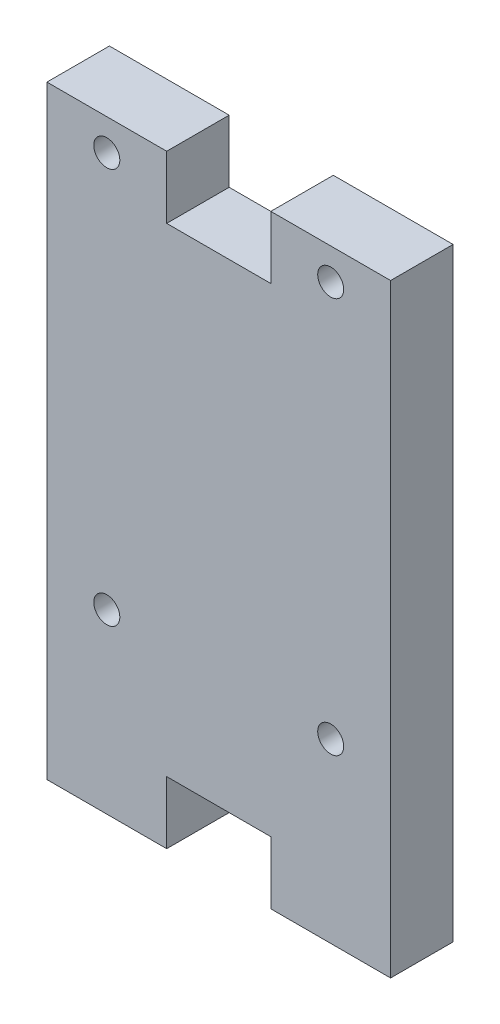
from build123d import *

# Parameters (mm, degrees)
BOSS_EXTRU_1_DEPTH      = 6
ESQUISSE2_R             = 1.25
ENL_V_MAT_EXTRU_1_DEPTH = 6


with BuildPart() as part:
    # Esquisse1 → Boss.-Extru.1 (new body)
    with BuildSketch(Plane.XY):
        Polygon((-16.5, 22), (-5, 22), (-5, 16), (5, 16), (5, 22), (16.5, 22), (16.5, -36), (5, -36), (5, -30), (-5, -30), (-5, -36), (-16.5, -36), align=None)
    extrude(amount=BOSS_EXTRU_1_DEPTH)

    # Esquisse2 → Enlèv. mat.-Extru.1 (cut)
    with BuildSketch(Plane.XY.offset(6)):
        with Locations((-10.75, 19)):
            Circle(ESQUISSE2_R)
        with Locations((10.75, 19)):
            Circle(ESQUISSE2_R)
        with Locations((10.75, -19)):
            Circle(ESQUISSE2_R)
        with Locations((-10.75, -19)):
            Circle(ESQUISSE2_R)
    extrude(amount=-ENL_V_MAT_EXTRU_1_DEPTH, mode=Mode.SUBTRACT)


solid = part.part
